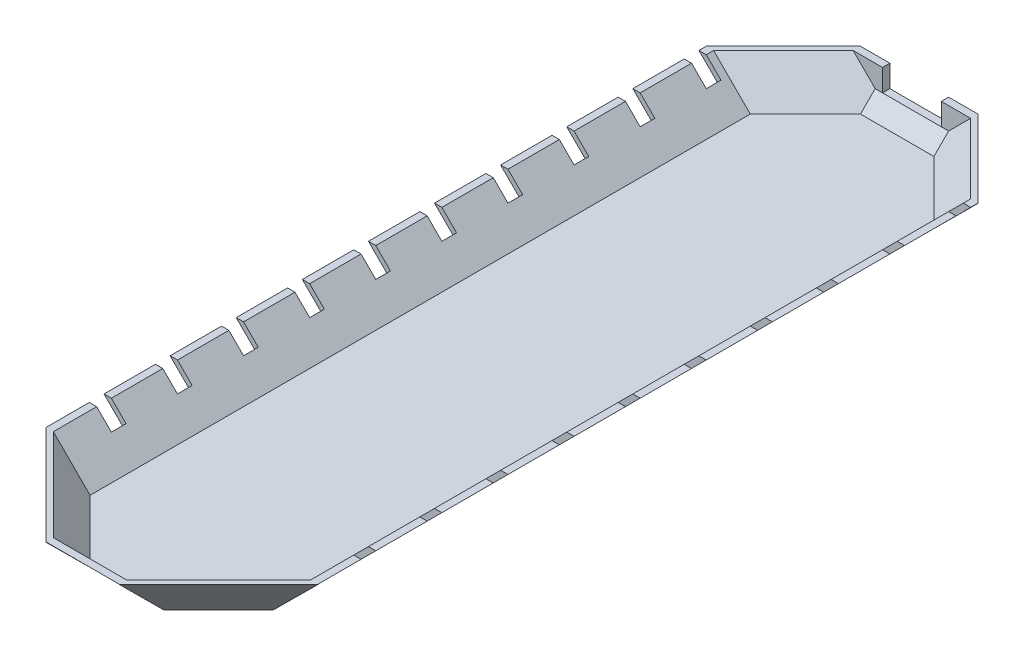
from build123d import *

# Parameters (mm, degrees)
BOSS_EXTRUDE1_DEPTH     = 5
BOSS_EXTRUDE2_DEPTH     = 224.75
BOSS_EXTRUDE3_DEPTH     = 25
SKETCH7_W               = 5
SKETCH7_H               = 5
BOSS_EXTRUDE5_DEPTH     = 15
BOSS_EXTRUDE6_DEPTH     = 50
BOSS_EXTRUDE7_DEPTH     = 48
BOSS_EXTRUDE8_DEPTH     = 48
BOSS_EXTRUDE9_DEPTH     = 48
CUT_EXTRUDE1_DEPTH      = 95.104275362
CUT_EXTRUDE1_DEPTH_BACK = 93.6900618
SKETCH20_W              = 50
SKETCH20_H              = 48.112885627
CUT_EXTRUDE2_DEPTH      = 105
CUT_EXTRUDE3_DEPTH      = 105
BOSS_EXTRUDE11_DEPTH    = 5
CUT_EXTRUDE4_DEPTH      = 293.4400618
CUT_EXTRUDE4_DEPTH_BACK = 278.247872606
CUT_EXTRUDE5_DEPTH      = 29
SKETCH25_W              = 15
SKETCH25_H              = 10
CUT_EXTRUDE6_DEPTH      = 26
CUT_EXTRUDE6_DEPTH_BACK = 6


with BuildPart() as part:
    # Sketch1 → Boss-Extrude1 (new body)
    with BuildSketch(Plane(origin=(0, 0, 0), x_dir=(1, 0, 0), z_dir=(0, 1, 0))):
        Polygon((62.497872606, -224.75), (62.497872606, 224.75), (25, 262.247872606), (-25, 262.247872606), (-62.497872606, 224.75), (-62.497872606, -224.75), (-25, -262.247872606), (25, -262.247872606), align=None)
    extrude(amount=BOSS_EXTRUDE1_DEPTH)

    # Sketch3 → Boss-Extrude2 (add, symmetric)
    with BuildSketch(Plane(origin=(0, 0, 0), x_dir=(0, -1, 0), z_dir=(0, 0, 1))):
        Polygon((0, 62.497872606), (-5, 62.497872606), (-30, 87.497872606), (-30, 92.497872606), align=None)
        Polygon((-30, -87.497872606), (-30, -92.497872606), (0, -62.497872606), (-5, -62.497872606), align=None)
    extrude(amount=BOSS_EXTRUDE2_DEPTH, both=True)

    # Sketch6 → Boss-Extrude3 (add, symmetric)
    with BuildSketch(Plane(origin=(0, 0, 0), x_dir=(0, -1, 0), z_dir=(-1, 0, 0))):
        Polygon((0, 262.247872606), (-30, 292.247872606), (-30, 287.247872606), (-5, 262.247872606), align=None)
        Polygon((0, -262.247872606), (-15, -277.247872606), (-15, -272.247872606), (-5, -262.247872606), align=None)
    extrude(amount=BOSS_EXTRUDE3_DEPTH, both=True)

    # Sketch7 → Boss-Extrude5 (add)
    with BuildSketch(Plane(origin=(0, 15, 0), x_dir=(1, 0, 0), z_dir=(0, 1, 0))):
        with Locations((-22.5, 274.747872606)):
            Rectangle(SKETCH7_W, SKETCH7_H)
        with Locations((22.5, 274.747872606)):
            Rectangle(SKETCH7_W, SKETCH7_H)
    extrude(amount=BOSS_EXTRUDE5_DEPTH)

    # Sketch10 → Boss-Extrude6 (add, symmetric)
    with BuildSketch(Plane(origin=(99.875, 0, -99.875), x_dir=(0, -1, 0), z_dir=(0.707106781, 0, -0.707106781))):
        Polygon((0, 203.114918601), (-30, 224.328122037), (-30, 220.792588131), (-5, 203.114918601), align=None)
    extrude(amount=BOSS_EXTRUDE6_DEPTH, both=True)

    # Sketch13 → Boss-Extrude7 (add, symmetric)
    with BuildSketch(Plane(origin=(-99.875, 0, -99.875), x_dir=(0, -1, 0), z_dir=(0.707106781, 0, 0.707106781))):
        Polygon((-5, 203.114918601), (-30, 220.792588131), (-30, 224.328122037), (0, 203.114918601), align=None)
    extrude(amount=BOSS_EXTRUDE7_DEPTH, both=True)

    # Sketch15 → Boss-Extrude8 (add, symmetric)
    with BuildSketch(Plane(origin=(-99.875, 0, 99.875), x_dir=(0, -1, 0), z_dir=(-0.707106781, 0, 0.707106781))):
        Polygon((-5, 203.114918601), (-30, 220.792588131), (-30, 224.328122037), (0, 203.114918601), align=None)
    extrude(amount=BOSS_EXTRUDE8_DEPTH, both=True)

    # Sketch17 → Boss-Extrude9 (add, symmetric)
    with BuildSketch(Plane(origin=(99.875, 0, 99.875), x_dir=(0, -1, 0), z_dir=(-0.707106781, 0, -0.707106781))):
        Polygon((-5, 203.114918601), (-30, 220.792588131), (-30, 224.328122037), (0, 203.114918601), align=None)
    extrude(amount=BOSS_EXTRUDE9_DEPTH, both=True)

    # Sketch18 → Cut-Extrude1 (cut, two sides)
    with BuildSketch(Plane(origin=(0, 0, 0), x_dir=(0, -1, 0), z_dir=(-1, 0, 0))) as cut_extrude1_sk:
        Polygon((0, 262.247872606), (-30, 292.4400618), (0, 277.4400618), align=None)
    extrude(amount=CUT_EXTRUDE1_DEPTH, mode=Mode.SUBTRACT)
    extrude(cut_extrude1_sk.sketch, amount=-CUT_EXTRUDE1_DEPTH_BACK, mode=Mode.SUBTRACT)

    # Sketch20 → Cut-Extrude2 (cut)
    with BuildSketch(Plane(origin=(0, -131.123936303, -131.123936303), x_dir=(1, 0, 0), z_dir=(0, -0.707106781, -0.707106781))):
        with Locations((0, -209.493691886)):
            Rectangle(SKETCH20_W, SKETCH20_H)
    extrude(amount=CUT_EXTRUDE2_DEPTH, mode=Mode.SUBTRACT)

    # Sketch21 → Cut-Extrude3 (cut)
    with BuildSketch(Plane(origin=(0, 0, -277.247872606), x_dir=(-1, 0, 0), z_dir=(0, 0, -1))):
        Polygon((20, 15), (-53.678843976, 15), (-53.678843976, 30), (47.571265033, 30), (47.571265033, 15), align=None)
    extrude(amount=CUT_EXTRUDE3_DEPTH, mode=Mode.SUBTRACT)

    # Sketch22 → Boss-Extrude11 (add)
    with BuildSketch(Plane(origin=(0, 0, -277.247872606), x_dir=(-1, 0, 0), z_dir=(0, 0, -1))):
        Polygon((-40, 30), (-25, 15), (-20, 15), (-20, 30), align=None)
        Polygon((20, 30), (40, 30), (25, 15), (20, 15), align=None)
    extrude(amount=-BOSS_EXTRUDE11_DEPTH)

    # Sketch23 → Cut-Extrude4 (cut, two sides)
    with BuildSketch(Plane(origin=(0, 0, 0), x_dir=(0, -1, 0), z_dir=(0, 0, 1))) as cut_extrude4_sk:
        Polygon((0, 62.497872606), (-30, 92.6900618), (0, 77.6900618), align=None)
    extrude(amount=CUT_EXTRUDE4_DEPTH, mode=Mode.SUBTRACT)
    extrude(cut_extrude4_sk.sketch, amount=-CUT_EXTRUDE4_DEPTH_BACK, mode=Mode.SUBTRACT)

    # Sketch24 → Cut-Extrude5 (cut)
    with BuildSketch(Plane(origin=(-31.248936303, -31.248936303, 0), x_dir=(0, 0, 1), z_dir=(-0.707106781, -0.707106781, 0))):
        Polygon((-224.75, 44.19266953), (-259.614343039, 44.19266953), (-259.614343039, 90.205869936), (275.937456007, 90.205869936), (275.937456007, 44.19266953), align=None)
    extrude(amount=CUT_EXTRUDE5_DEPTH, mode=Mode.SUBTRACT)

    # Sketch25 → Cut-Extrude6 (cut, two sides)
    with BuildSketch(Plane(origin=(0, 5, 0), x_dir=(1, 0, 0), z_dir=(0, 1, 0))) as cut_extrude6_sk:
        with Locations((84.997872606, 214.75)):
            Rectangle(SKETCH25_W, SKETCH25_H)
        with Locations((84.997872606, 169.75)):
            Rectangle(SKETCH25_W, SKETCH25_H)
        with Locations((84.997872606, 124.75)):
            Rectangle(SKETCH25_W, SKETCH25_H)
        with Locations((84.997872606, 79.75)):
            Rectangle(SKETCH25_W, SKETCH25_H)
        with Locations((84.997872606, 34.75)):
            Rectangle(SKETCH25_W, SKETCH25_H)
        with Locations((84.997872606, -10.25)):
            Rectangle(SKETCH25_W, SKETCH25_H)
        with Locations((84.997872606, -55.25)):
            Rectangle(SKETCH25_W, SKETCH25_H)
        with Locations((84.997872606, -190.25)):
            Rectangle(SKETCH25_W, SKETCH25_H)
        with Locations((84.997872606, -145.25)):
            Rectangle(SKETCH25_W, SKETCH25_H)
        with Locations((84.997872606, -100.25)):
            Rectangle(SKETCH25_W, SKETCH25_H)
        with Locations((-84.997872606, -190.25)):
            Rectangle(SKETCH25_W, SKETCH25_H)
        with Locations((-84.997872606, -145.25)):
            Rectangle(SKETCH25_W, SKETCH25_H)
        with Locations((-84.997872606, -100.25)):
            Rectangle(SKETCH25_W, SKETCH25_H)
        with Locations((-84.997872606, -55.25)):
            Rectangle(SKETCH25_W, SKETCH25_H)
        with Locations((-84.997872606, 34.75)):
            Rectangle(SKETCH25_W, SKETCH25_H)
        with Locations((-84.997872606, 214.75)):
            Rectangle(SKETCH25_W, SKETCH25_H)
        with Locations((-84.997872606, 169.75)):
            Rectangle(SKETCH25_W, SKETCH25_H)
        with Locations((-84.997872606, 124.75)):
            Rectangle(SKETCH25_W, SKETCH25_H)
        with Locations((-84.997872606, 79.75)):
            Rectangle(SKETCH25_W, SKETCH25_H)
        with Locations((-84.997872606, -10.25)):
            Rectangle(SKETCH25_W, SKETCH25_H)
    extrude(amount=CUT_EXTRUDE6_DEPTH, mode=Mode.SUBTRACT)
    extrude(cut_extrude6_sk.sketch, amount=-CUT_EXTRUDE6_DEPTH_BACK, mode=Mode.SUBTRACT)


solid = part.part
